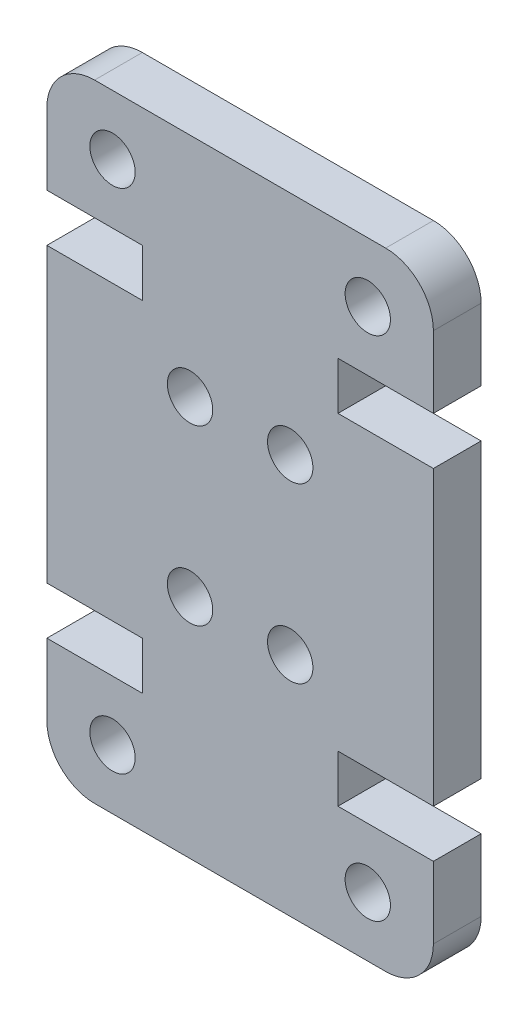
from build123d import *

# Parameters (mm, degrees)
SKETCH2_R           = 0.95
BOSS_EXTRUDE1_DEPTH = 4
SKETCH3_W           = 16.2
SKETCH3_H           = 26.26
CUT_EXTRUDE1_DEPTH  = 2


with BuildPart() as part:
    # Sketch2 → Boss-Extrude1 (new body)
    with BuildSketch(Plane.XY):
        with BuildLine():
            Line((0, 7), (0, 19.26))
            Line((0, 19.26), (4, 19.26))
            Line((4, 19.26), (4, 21.26))
            Line((4, 21.26), (0, 21.26))
            Line((0, 21.26), (0, 24.26))
            ThreePointArc((0, 24.26), (0.585786438, 25.674213562), (2, 26.26))
            Line((2, 26.26), (14.2, 26.26))
            ThreePointArc((14.2, 26.26), (15.614213562, 25.674213562), (16.2, 24.26))
            Line((16.2, 24.26), (16.2, 21.26))
            Line((16.2, 21.26), (12.2, 21.26))
            Line((12.2, 21.26), (12.2, 19.26))
            Line((12.2, 19.26), (16.2, 19.26))
            Line((16.2, 19.26), (16.2, 7))
            Line((16.2, 7), (12.2, 7))
            Line((12.2, 7), (12.2, 5))
            Line((12.2, 5), (16.2, 5))
            Line((16.2, 5), (16.2, 2))
            ThreePointArc((16.2, 2), (15.614213562, 0.585786438), (14.2, 0))
            Line((14.2, 0), (2, 0))
            ThreePointArc((2, 0), (0.585786438, 0.585786438), (0, 2))
            Line((0, 2), (0, 5))
            Line((0, 5), (4, 5))
            Line((4, 5), (4, 7))
            Line((4, 7), (0, 7))
        make_face()
        with Locations((13.45, 2.5)):
            Circle(SKETCH2_R, mode=Mode.SUBTRACT)
        with Locations((10.2, 9.5)):
            Circle(SKETCH2_R, mode=Mode.SUBTRACT)
        with Locations((2.75, 23.76)):
            Circle(SKETCH2_R, mode=Mode.SUBTRACT)
        with Locations((6, 16.76)):
            Circle(SKETCH2_R, mode=Mode.SUBTRACT)
        with Locations((10.2, 16.76)):
            Circle(SKETCH2_R, mode=Mode.SUBTRACT)
        with Locations((13.45, 23.76)):
            Circle(SKETCH2_R, mode=Mode.SUBTRACT)
        with Locations((6, 9.5)):
            Circle(SKETCH2_R, mode=Mode.SUBTRACT)
        with Locations((2.75, 2.5)):
            Circle(SKETCH2_R, mode=Mode.SUBTRACT)
    extrude(amount=BOSS_EXTRUDE1_DEPTH)

    # Sketch3 → Cut-Extrude1 (cut)
    with BuildSketch(Plane.XY.offset(4)):
        with Locations((8.1, 13.13)):
            Rectangle(SKETCH3_W, SKETCH3_H)
    extrude(amount=-CUT_EXTRUDE1_DEPTH, mode=Mode.SUBTRACT)


solid = part.part
